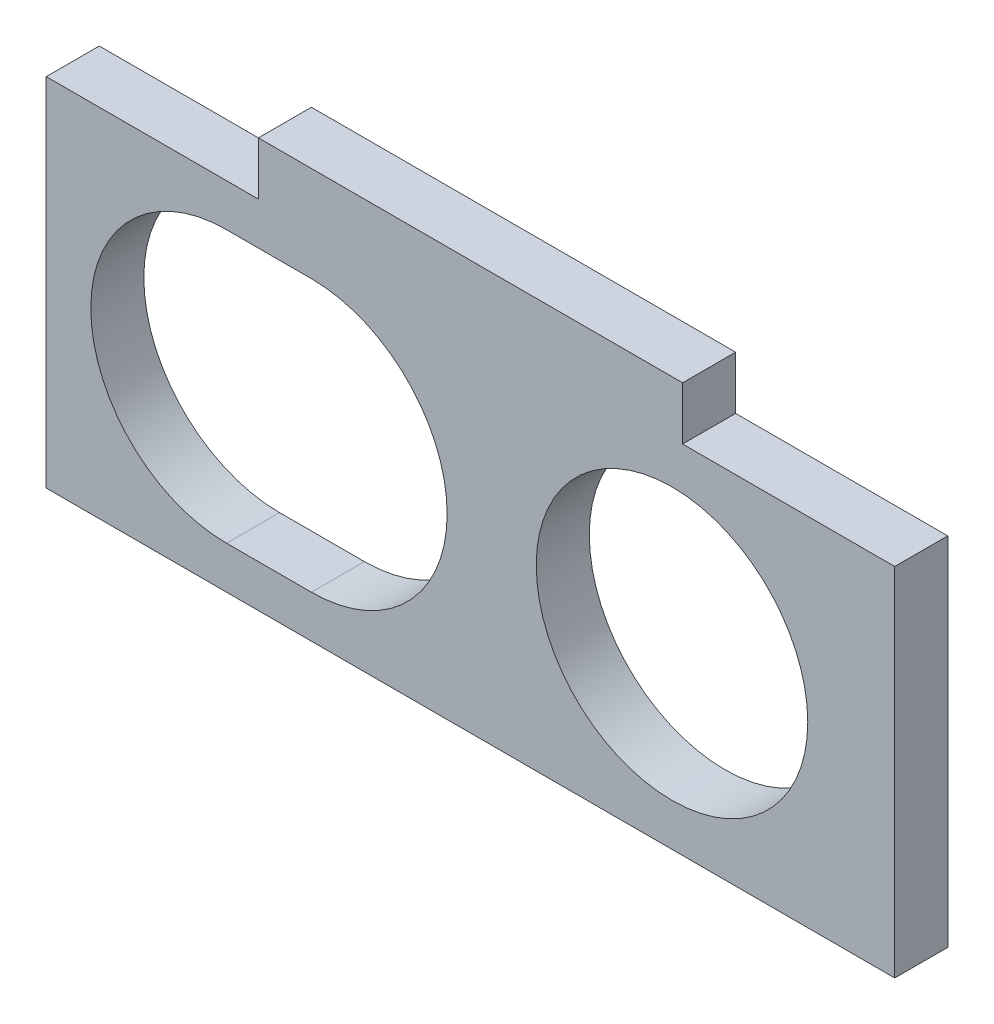
from build123d import *

# Parameters (mm, degrees)
SKETCH1_W           = 50.8
SKETCH1_H           = 24.511
BOSS_EXTRUDE1_DEPTH = 3.175
SKETCH2_R           = 8.128
SKETCH2_W           = 12.7
SKETCH2_H           = 3.175
CUT_EXTRUDE1_DEPTH  = 3.175


with BuildPart() as part:
    # Sketch1 → Boss-Extrude1 (new body)
    with BuildSketch(Plane.XY):
        Rectangle(SKETCH1_W, SKETCH1_H)
    extrude(amount=BOSS_EXTRUDE1_DEPTH)

    # Sketch2 → Cut-Extrude1 (cut)
    with BuildSketch(Plane.XY.offset(3.175)):
        with Locations((12.065, -1.5875)):
            Circle(SKETCH2_R)
        with Locations((-19.05, 10.668)):
            Rectangle(SKETCH2_W, SKETCH2_H)
        with Locations((19.05, 10.668)):
            Rectangle(SKETCH2_W, SKETCH2_H)
        with BuildLine():
            Line((-14.605, 6.5405), (-9.525, 6.5405))
            ThreePointArc((-9.525, 6.5405), (-1.397, -1.5875), (-9.525, -9.7155))
            Line((-9.525, -9.7155), (-14.605, -9.7155))
            ThreePointArc((-14.605, -9.7155), (-22.733, -1.5875), (-14.605, 6.5405))
        make_face()
    extrude(amount=-CUT_EXTRUDE1_DEPTH, mode=Mode.SUBTRACT)


solid = part.part
